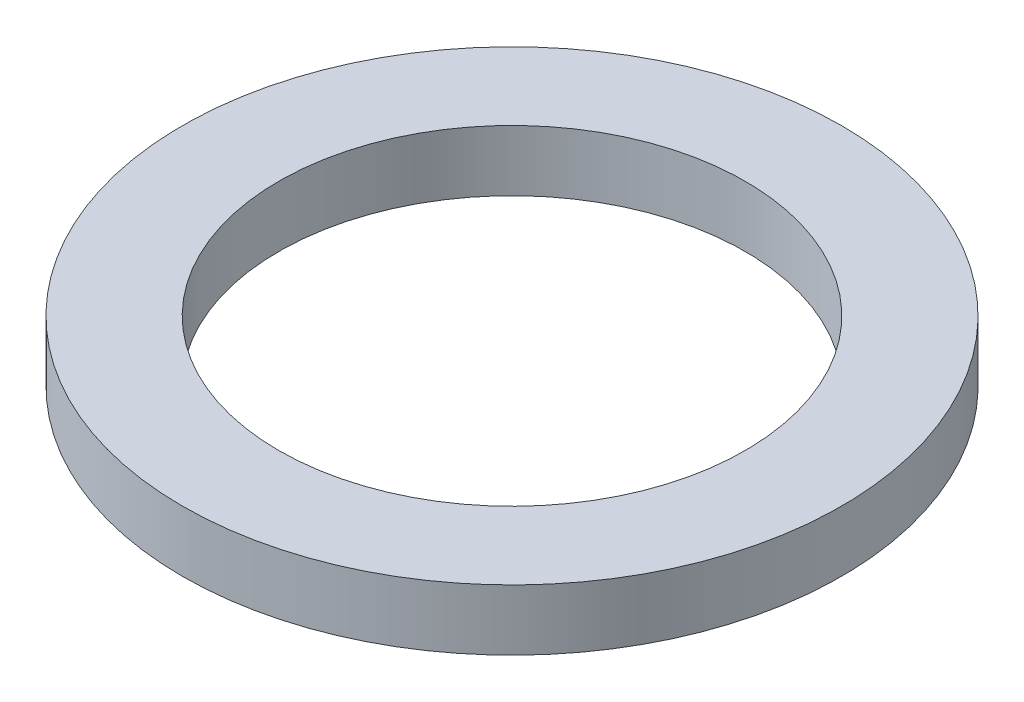
from build123d import *

# Parameters (mm, degrees)
SKETCH1_R      = 32.5
SKETCH1_R_2    = 23
EXTRUDE1_DEPTH = 6


with BuildPart() as part:
    # Sketch1 → Extrude1 (new body)
    with BuildSketch(Plane(origin=(0, 0, 0), x_dir=(1, 0, 0), z_dir=(0, 1, 0))):
        Circle(SKETCH1_R)
        Circle(SKETCH1_R_2, mode=Mode.SUBTRACT)
    extrude(amount=EXTRUDE1_DEPTH)


solid = part.part
